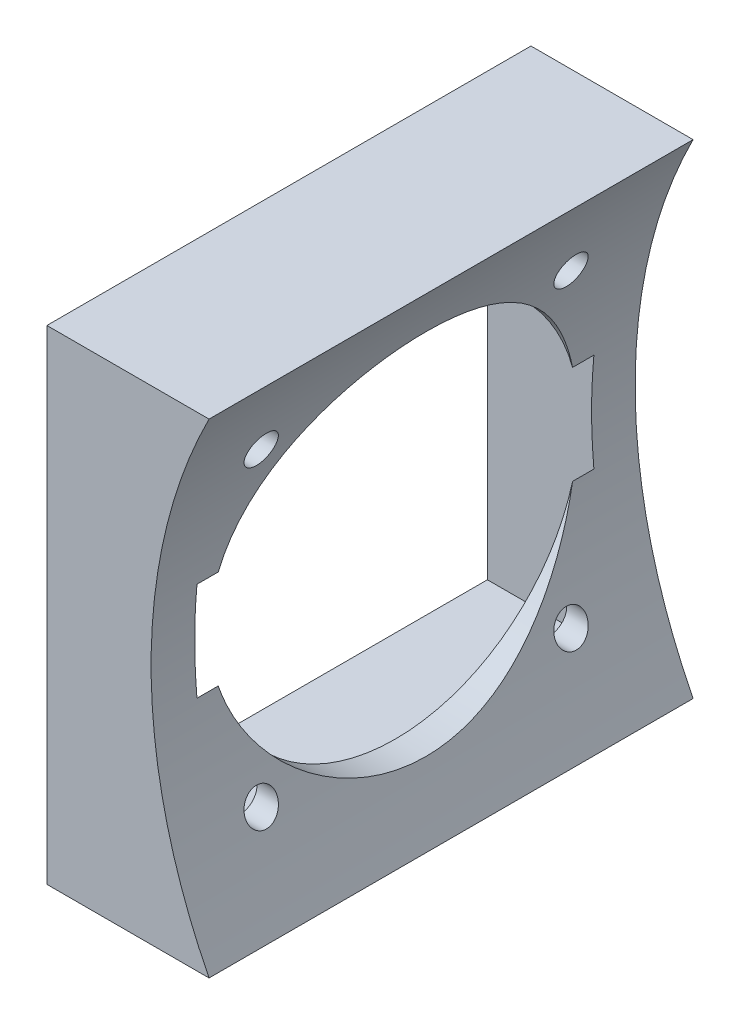
from build123d import *

# Parameters (mm, degrees)
SALIENTE_EXTRUIR1_DEPTH = 50
CROQUIS2_W              = 41
CROQUIS2_H              = 41
CORTAR_EXTRUIR1_DEPTH   = 11
CROQUIS3_R              = 1.7
CROQUIS3_R_2            = 19
CORTAR_EXTRUIR2_DEPTH   = 11


with BuildPart() as part:
    # Croquis1 → Saliente-Extruir1 (new body)
    with BuildSketch(Plane.XY):
        with BuildLine():
            Line((8.375, -25), (-8.375, -25))
            Line((-8.375, -25), (-8.375, 25))
            Line((-8.375, 25), (8.375, 25))
            ThreePointArc((8.375, 25), (2.389225586, 0), (8.375, -25))
        make_face()
    extrude(amount=SALIENTE_EXTRUIR1_DEPTH)

    # Croquis2 → Cortar-Extruir1 (cut)
    with BuildSketch(Plane.ZY.offset(8.375)):
        with Locations((25, 0)):
            Rectangle(CROQUIS2_W, CROQUIS2_H)
    extrude(amount=-CORTAR_EXTRUIR1_DEPTH, mode=Mode.SUBTRACT)

    # Croquis3 → Cortar-Extruir2 (cut)
    with BuildSketch(Plane.ZY.offset(-2.625)):
        with Locations((9, 16)):
            Circle(CROQUIS3_R)
        with Locations((41, 16)):
            Circle(CROQUIS3_R)
        with Locations((41, -16)):
            Circle(CROQUIS3_R)
        with Locations((9, -16)):
            Circle(CROQUIS3_R)
        with Locations((25, 0)):
            Circle(CROQUIS3_R_2)
    extrude(amount=-CORTAR_EXTRUIR2_DEPTH, mode=Mode.SUBTRACT)


solid = part.part
